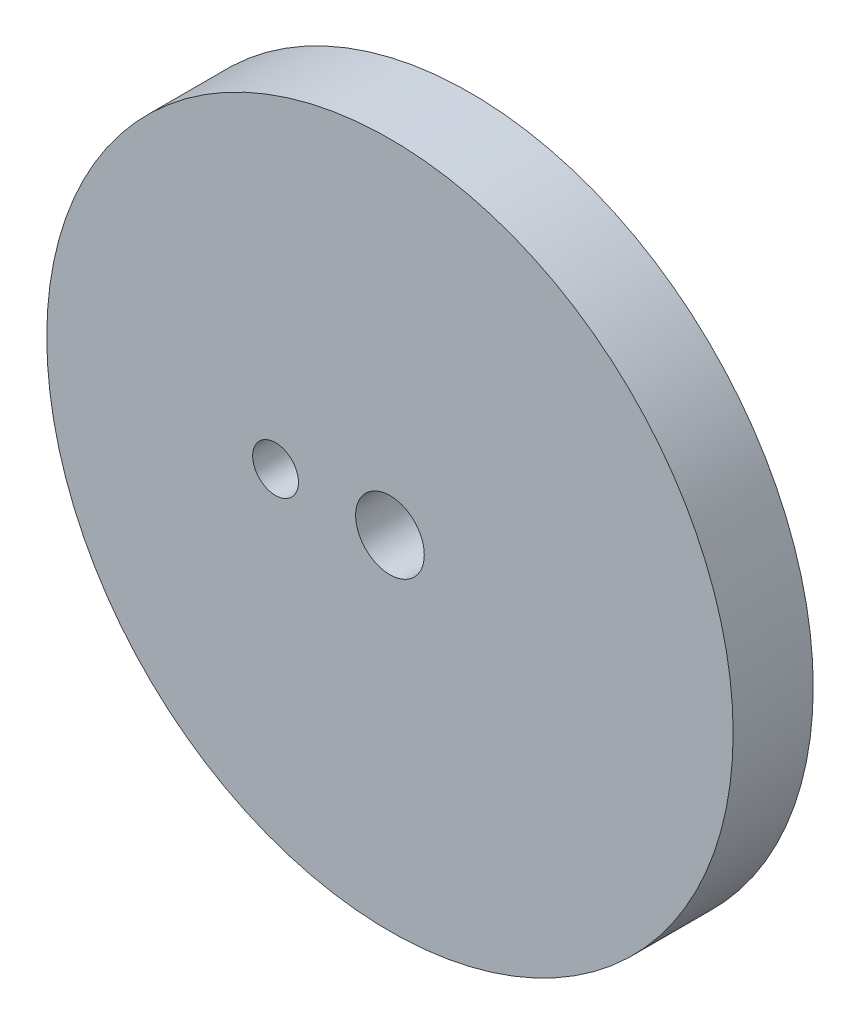
from build123d import *

# Parameters (mm, degrees)
ESQUISSE1_R      = 30
ESQUISSE1_R_2    = 3
ESQUISSE1_R_3    = 2
EXTRUSION1_DEPTH = 7


with BuildPart() as part:
    # Esquisse1 → Extrusion1 (new body)
    with BuildSketch(Plane.XY):
        Circle(ESQUISSE1_R)
        Circle(ESQUISSE1_R_2, mode=Mode.SUBTRACT)
        with Locations((-10, 0)):
            Circle(ESQUISSE1_R_3, mode=Mode.SUBTRACT)
    extrude(amount=EXTRUSION1_DEPTH)


solid = part.part
